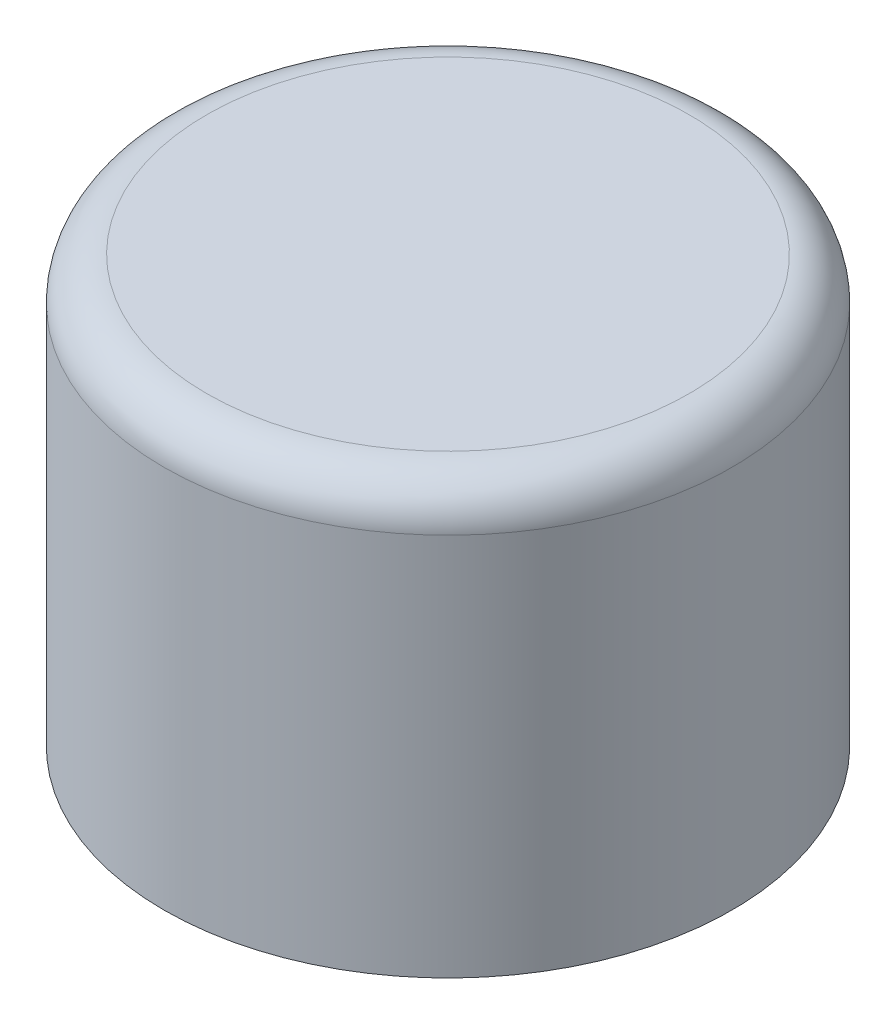
from build123d import *

# Parameters (mm, degrees)
ESQUISSE1_R      = 2
EXTRUSION1_DEPTH = 3
CONG_1_R         = 0.3


with BuildPart() as part:
    # Esquisse1 → Extrusion1 (new body)
    with BuildSketch(Plane(origin=(0, 0, 0), x_dir=(1, 0, 0), z_dir=(0, 1, 0))):
        with Locations(Location((0, 0, 0), (0, 0, 270))):  # turned: the seam where the file's is
            Circle(ESQUISSE1_R)
    extrude(amount=EXTRUSION1_DEPTH)

    # Congé1
    cong_1_edges = [part.edges().sort_by_distance(p)[0] for p in [
        (0, 3, -2),
    ]]
    fillet(cong_1_edges, radius=CONG_1_R)


solid = part.part
